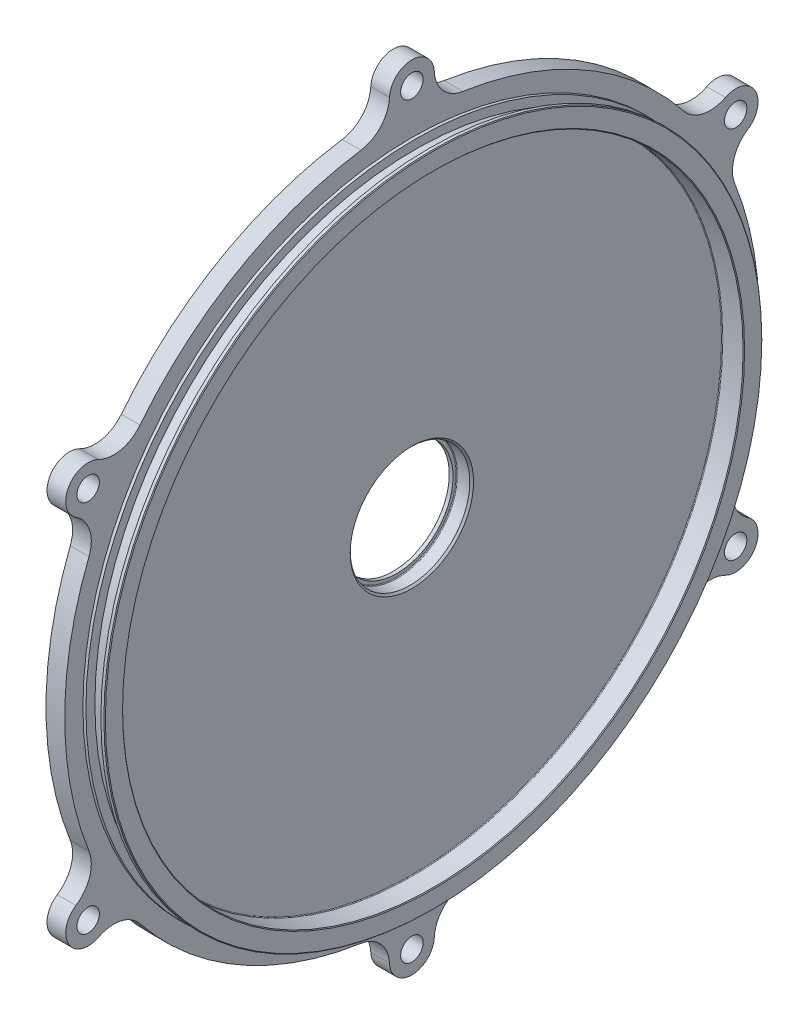
from build123d import *

# Parameters (mm, degrees)
SKETCH2_R           = 92.875
SKETCH2_R_2         = 16
BOSS_EXTRUDE1_DEPTH = 5
SKETCH3_R           = 6
SKETCH3_R_2         = 3
BOSS_EXTRUDE2_DEPTH = 5
CIRPATTERN1_COUNT   = 6
BOSS_EXTRUDE3_START = -12
SKETCH4_R           = 16
SKETCH4_R_2         = 15
BOSS_EXTRUDE3_DEPTH = 1
FILLET1_R           = 0.2
CHAMFER1_SIZE       = 0.5
SKETCH5_R           = 88
SKETCH5_R_2         = 83
BOSS_EXTRUDE4_DEPTH = 5.8
CHAMFER2_SIZE       = 0.2
FILLET2_R           = 0.2
CUT_EXTRUDE1_START  = -0.8
SKETCH6_R           = 88
SKETCH6_R_2         = 85.6
CUT_EXTRUDE1_DEPTH  = 4


with BuildPart() as part:
    # Sketch2 → Boss-Extrude1 (new body)
    with BuildSketch(Plane.ZY.offset(7)):
        Circle(SKETCH2_R)
        Circle(SKETCH2_R_2, mode=Mode.SUBTRACT)
    extrude(amount=BOSS_EXTRUDE1_DEPTH)

    # Sketch3 → Boss-Extrude2 (add)
    with BuildSketch(Plane.ZY.offset(7)):
        with Locations((0, 100)):
            Circle(SKETCH3_R)
        with Locations((0, 100)):
            Circle(SKETCH3_R_2, mode=Mode.SUBTRACT)
        with BuildLine():
            ThreePointArc((-13.656930681, 91.865411714), (0, 92.875), (13.656930681, 91.865411714))
            ThreePointArc((13.656930681, 91.865411714), (8.317192306, 94.717589922), (5.992139168, 100.30703125))
            ThreePointArc((5.992139168, 100.30703125), (5.99803447, 100.153565931), (6, 100))
            ThreePointArc((6, 100), (-0.153565931, 94.00196553), (-5.992139168, 100.30703125))
            ThreePointArc((-5.992139168, 100.30703125), (-8.317192306, 94.717589922), (-13.656930681, 91.865411714))
        make_face()
    boss_extrude2 = extrude(amount=BOSS_EXTRUDE2_DEPTH)

    # CirPattern1: Boss-Extrude2 ×6 about axis
    cirpattern1_axis = Axis((0, 0, 0), (1, 0, 0))
    for i in range(1, CIRPATTERN1_COUNT):
        add(boss_extrude2.rotate(cirpattern1_axis, i * 360 / CIRPATTERN1_COUNT))

    # Sketch4 → Boss-Extrude3 (add)
    with BuildSketch(Plane(origin=(0, 0, 0), x_dir=(0, 0, -1), z_dir=(1, 0, 0)).offset(BOSS_EXTRUDE3_START)):
        Circle(SKETCH4_R)
        Circle(SKETCH4_R_2, mode=Mode.SUBTRACT)
    extrude(amount=BOSS_EXTRUDE3_DEPTH)

    # Fillet1
    fillet1_edges = [part.edges().sort_by_distance(p)[0] for p in [
        (-11, 0, -16),
    ]]
    fillet(fillet1_edges, radius=FILLET1_R)

    # Chamfer1
    chamfer1_edges = [part.edges().sort_by_distance(p)[0] for p in [
        (-7, 0, -16),
    ]]
    chamfer(chamfer1_edges, length=CHAMFER1_SIZE)

    # Sketch5 → Boss-Extrude4 (add)
    with BuildSketch(Plane.ZY.offset(7)):
        Circle(SKETCH5_R)
        Circle(SKETCH5_R_2, mode=Mode.SUBTRACT)
    extrude(amount=-BOSS_EXTRUDE4_DEPTH)

    # Chamfer2
    chamfer2_edges = [part.edges().sort_by_distance(p)[0] for p in [
        (-1.2, 0, -88),
        (-1.2, 0, -83),
    ]]
    chamfer(chamfer2_edges, length=CHAMFER2_SIZE)

    # Fillet2
    fillet2_edges = [part.edges().sort_by_distance(p)[0] for p in [
        (-7, 0, -83),
    ]]
    fillet(fillet2_edges, radius=FILLET2_R)

    # Sketch6 → Cut-Extrude1 (cut)
    with BuildSketch(Plane.ZY.offset(7).offset(CUT_EXTRUDE1_START)):
        Circle(SKETCH6_R)
        Circle(SKETCH6_R_2, mode=Mode.SUBTRACT)
    extrude(amount=-CUT_EXTRUDE1_DEPTH, mode=Mode.SUBTRACT)


solid = part.part
